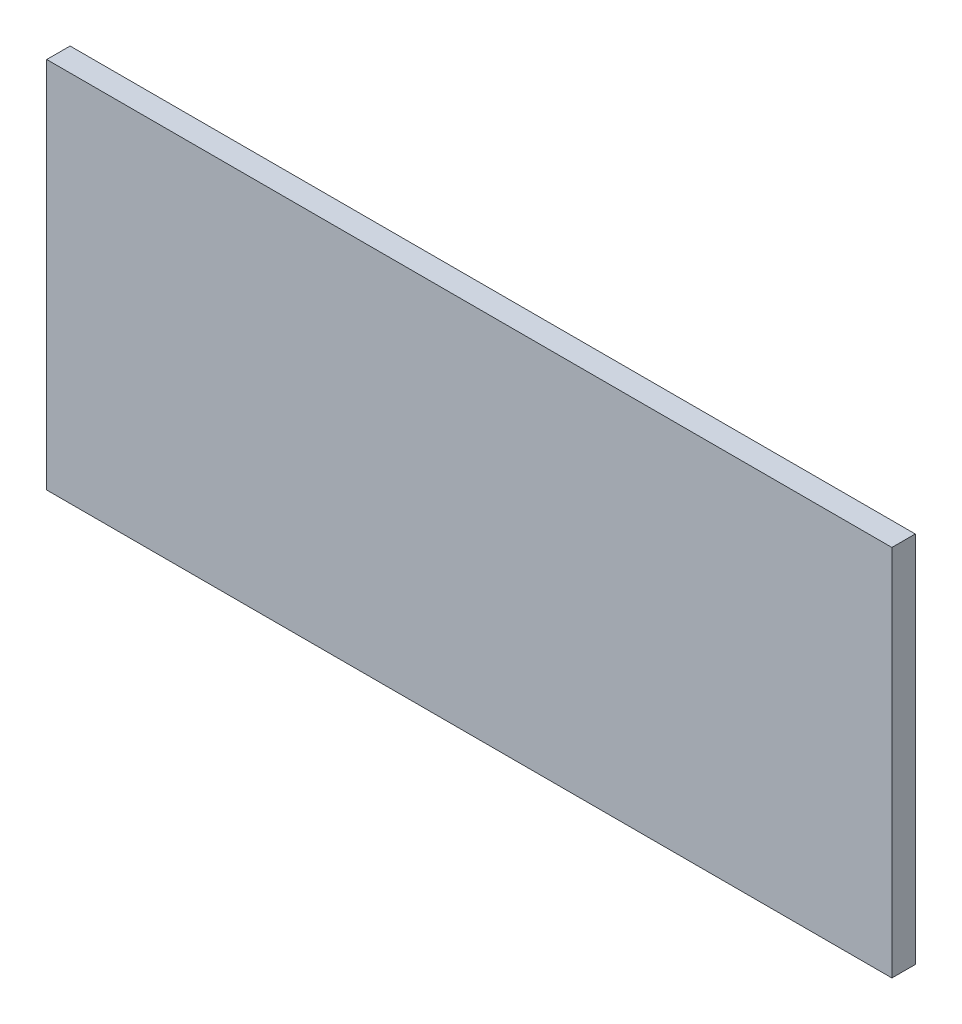
from build123d import *

# Parameters (mm, degrees)
SKETCH1_W           = 431.8
SKETCH1_H           = 190.5
BOSS_EXTRUDE1_DEPTH = 11.938


with BuildPart() as part:
    # Sketch1 → Boss-Extrude1 (new body)
    with BuildSketch(Plane.XY):
        Rectangle(SKETCH1_W, SKETCH1_H)
    extrude(amount=BOSS_EXTRUDE1_DEPTH)


solid = part.part
